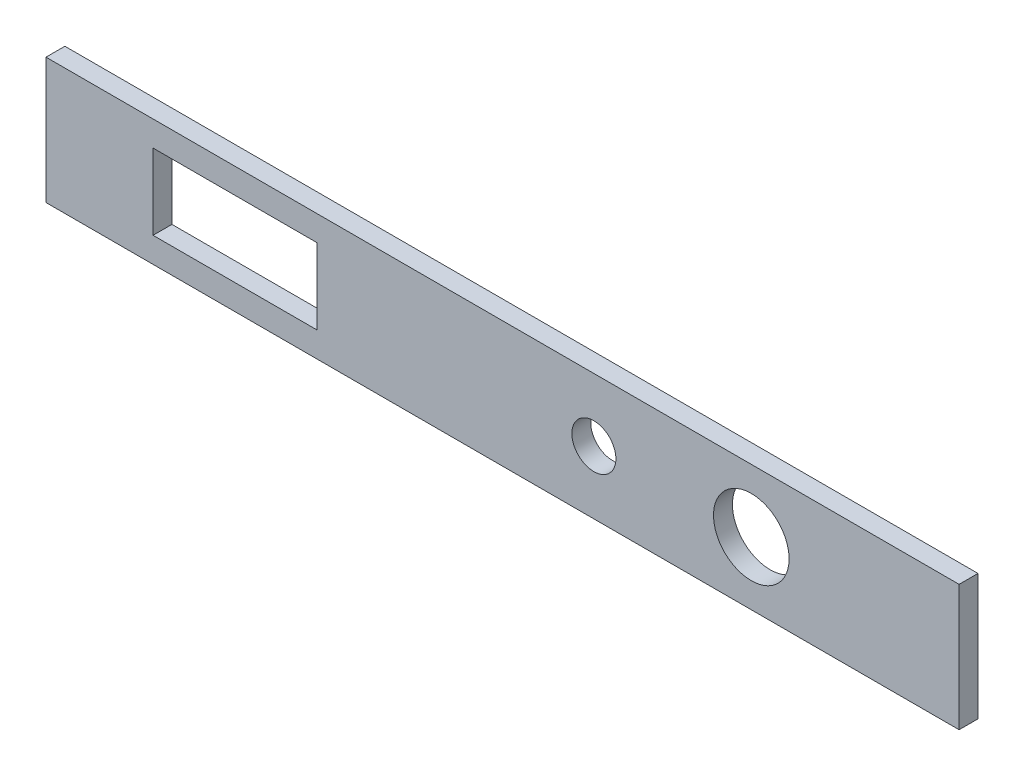
from build123d import *

# Parameters (mm, degrees)
SKETCH1_W           = 145
SKETCH1_H           = 20
BOSS_EXTRUDE1_DEPTH = 3
SKETCH2_R           = 3.5
SKETCH2_R_2         = 6
SKETCH2_W           = 26
SKETCH2_H           = 12
CUT_EXTRUDE1_DEPTH  = 4


with BuildPart() as part:
    # Sketch1 → Boss-Extrude1 (new body)
    with BuildSketch(Plane.XY):
        with Locations((72.5, 10)):
            Rectangle(SKETCH1_W, SKETCH1_H)
    extrude(amount=BOSS_EXTRUDE1_DEPTH)

    # Sketch2 → Cut-Extrude1 (cut, through all)
    with BuildSketch(Plane.XY.offset(3)):
        with Locations((87, 10)):
            Circle(SKETCH2_R)
        with Locations((112, 10)):
            Circle(SKETCH2_R_2)
        with Locations((30, 10)):
            Rectangle(SKETCH2_W, SKETCH2_H)
    extrude(amount=-CUT_EXTRUDE1_DEPTH, mode=Mode.SUBTRACT)


solid = part.part
